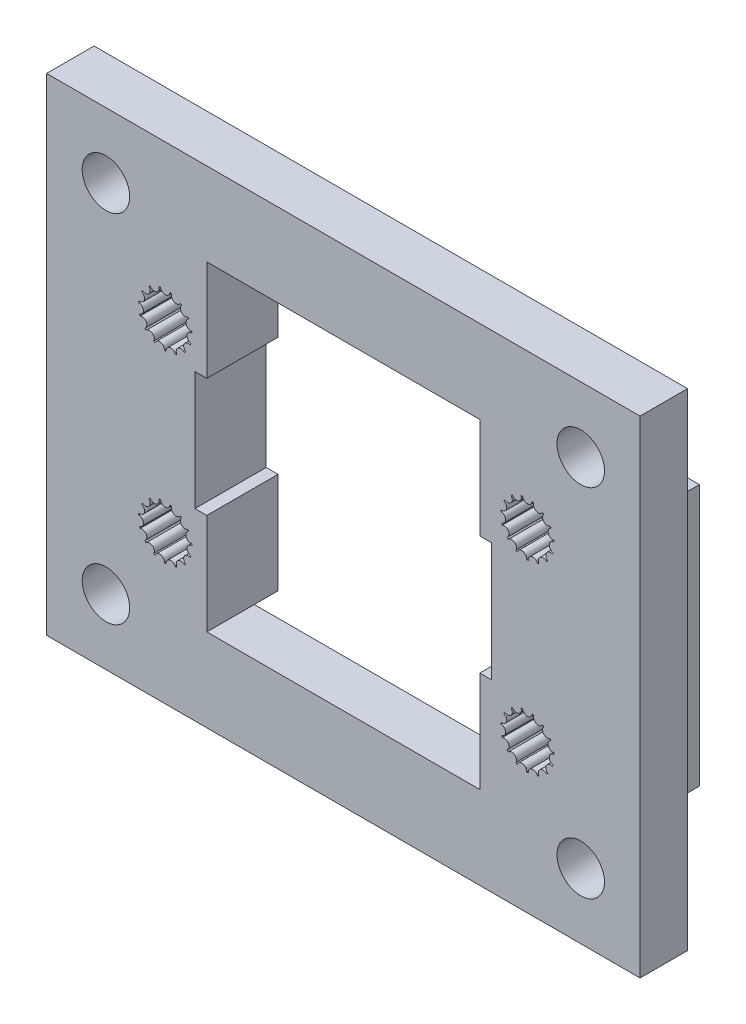
from build123d import *

# Parameters (mm, degrees)
SKETCH3_W               = 50
SKETCH3_H               = 35
BOSS_EXTRUDE2_DEPTH     = 10
CUT_EXTRUDE1_DEPTH      = 16
LPATTERN1_COUNT         = 2
LPATTERN1_PITCH         = 15.5
LPATTERN1_COUNT_DIR2    = 2
LPATTERN1_PITCH_DIR2    = 30.51
SKETCH4_W               = 50
SKETCH4_H               = 35
SKETCH4_W_2             = 42
SKETCH4_H_2             = 27
CUT_EXTRUDE2_DEPTH      = 6
SKETCH5_W               = 25
SKETCH5_H               = 10
CUT_EXTRUDE4_DEPTH      = 24
SKETCH6_R               = 2
CUT_EXTRUDE5_DEPTH      = 24
CUT_EXTRUDE6_DEPTH      = 24
MIRROR2_COPY_1_SKETCH_R = 2
MIRROR2_COPY_1_DEPTH    = 24
MIRROR2_COPY_2_DEPTH    = 24
SKETCH9_W               = 50
SKETCH9_H               = 3
BOSS_EXTRUDE4_DEPTH     = 4
SKETCH10_W              = 43
SKETCH10_H              = 28
CUT_EXTRUDE7_DEPTH      = 4
SKETCH11_W              = 2
SKETCH11_H              = 22
BOSS_EXTRUDE5_DEPTH     = 3
SKETCH12_W              = 23
SKETCH12_H              = 27
CUT_EXTRUDE8_DEPTH      = 17
SKETCH13_W              = 43.2
SKETCH13_H              = 32.4
CUT_EXTRUDE9_DEPTH      = 1


with BuildPart() as part:
    # Sketch3 → Boss-Extrude2 (new body)
    with BuildSketch(Plane.XY):
        with Locations((15, 7.5)):
            Rectangle(SKETCH3_W, SKETCH3_H)
    extrude(amount=BOSS_EXTRUDE2_DEPTH)

    # Sketch1 → Cut-Extrude1 (cut)
    with BuildSketch(Plane.XY):
        with BuildLine():
            ThreePointArc((0.398416619, 17.214444444), (0, 16.85), (-0.398416619, 17.214444444))
            ThreePointArc((-0.398416619, 17.214444444), (-0.467801304, 17.200832102), (-0.536724007, 17.185046302))
            ThreePointArc((-0.536724007, 17.185046302), (-0.75246279, 16.690059097), (-1.264667392, 16.860945025))
            ThreePointArc((-1.264667392, 16.860945025), (-1.322516818, 16.820288237), (-1.379060176, 16.777833803))
            ThreePointArc((-1.379060176, 16.777833803), (-1.374817927, 16.237891622), (-1.912245684, 16.185671305))
            ThreePointArc((-1.912245684, 16.185671305), (-1.948557159, 16.125), (-1.982944313, 16.063217688))
            ThreePointArc((-1.982944313, 16.063217688), (-1.759454555, 15.57168144), (-2.229179325, 15.305384245))
            ThreePointArc((-2.229179325, 15.305384245), (-2.237674265, 15.235189042), (-2.243959363, 15.164761577))
            ThreePointArc((-2.243959363, 15.164761577), (-1.839865506, 14.806622343), (-2.160667609, 14.372293474))
            ThreePointArc((-2.160667609, 14.372293474), (-2.139877162, 14.304711763), (-2.116973454, 14.237816691))
            ThreePointArc((-2.116973454, 14.237816691), (-1.602146997, 14.075), (-1.718556835, 13.547738864))
            ThreePointArc((-1.718556835, 13.547738864), (-1.672075857, 13.494456136), (-1.623943602, 13.442660224))
            ThreePointArc((-1.623943602, 13.442660224), (-1.087402717, 13.50331856), (-0.979291971, 12.974293398))
            ThreePointArc((-0.979291971, 12.974293398), (-0.915157447, 12.94452272), (-0.850119149, 12.916781953))
            ThreePointArc((-0.850119149, 12.916781953), (-0.384636628, 13.190426939), (-0.070698628, 12.751111007))
            ThreePointArc((-0.070698628, 12.751111007), (0, 12.75), (0.070698628, 12.751111007))
            ThreePointArc((0.070698628, 12.751111007), (0.384636628, 13.190426939), (0.850119149, 12.916781953))
            ThreePointArc((0.850119149, 12.916781953), (0.915157447, 12.94452272), (0.979291971, 12.974293398))
            ThreePointArc((0.979291971, 12.974293398), (1.087402717, 13.50331856), (1.623943602, 13.442660224))
            ThreePointArc((1.623943602, 13.442660224), (1.672075857, 13.494456136), (1.718556835, 13.547738864))
            ThreePointArc((1.718556835, 13.547738864), (1.602146997, 14.075), (2.116973454, 14.237816691))
            ThreePointArc((2.116973454, 14.237816691), (2.139877162, 14.304711763), (2.160667609, 14.372293474))
            ThreePointArc((2.160667609, 14.372293474), (1.839865506, 14.806622343), (2.243959363, 15.164761577))
            ThreePointArc((2.243959363, 15.164761577), (2.237674265, 15.235189042), (2.229179325, 15.305384245))
            ThreePointArc((2.229179325, 15.305384245), (1.759454555, 15.57168144), (1.982944313, 16.063217688))
            ThreePointArc((1.982944313, 16.063217688), (1.948557159, 16.125), (1.912245684, 16.185671305))
            ThreePointArc((1.912245684, 16.185671305), (1.374817927, 16.237891622), (1.379060176, 16.777833803))
            ThreePointArc((1.379060176, 16.777833803), (1.322516818, 16.820288237), (1.264667392, 16.860945025))
            ThreePointArc((1.264667392, 16.860945025), (0.75246279, 16.690059097), (0.536724007, 17.185046302))
            ThreePointArc((0.536724007, 17.185046302), (0.467801304, 17.200832102), (0.398416619, 17.214444444))
        make_face()
    cut_extrude1 = extrude(amount=CUT_EXTRUDE1_DEPTH, mode=Mode.SUBTRACT)

    # LPattern1: Cut-Extrude1 2 × 2
    with Locations(*[(j * LPATTERN1_PITCH_DIR2, -i * LPATTERN1_PITCH, 0) for i in range(LPATTERN1_COUNT) for j in range(LPATTERN1_COUNT_DIR2) if (i, j) != (0, 0)]):
        add(cut_extrude1, mode=Mode.SUBTRACT)

    # Sketch4 → Cut-Extrude2 (cut)
    with BuildSketch(Plane(origin=(0, 0, 0), x_dir=(-1, 0, 0), z_dir=(0, 0, -1))):
        with Locations((-15, 7.5)):
            Rectangle(SKETCH4_W, SKETCH4_H)
        with Locations((-15, 7.5)):
            Rectangle(SKETCH4_W_2, SKETCH4_H_2, mode=Mode.SUBTRACT)
    extrude(amount=-CUT_EXTRUDE2_DEPTH, mode=Mode.SUBTRACT)

    # Sketch5 → Cut-Extrude4 (cut)
    with BuildSketch(Plane(origin=(0, 0, 0), x_dir=(-1, 0, 0), z_dir=(0, 0, -1))):
        with Locations((-15, 7.5)):
            Rectangle(SKETCH5_W, SKETCH5_H)
    extrude(amount=-CUT_EXTRUDE4_DEPTH, mode=Mode.SUBTRACT)

    # Sketch6 → Cut-Extrude5 (cut, symmetric)
    with BuildSketch(Plane(origin=(0, 0, 6), x_dir=(-1, 0, 0), z_dir=(0, 0, -1))):
        with Locations((5, 22.5)):
            Circle(SKETCH6_R)
    cut_extrude5 = extrude(amount=CUT_EXTRUDE5_DEPTH, both=True, mode=Mode.SUBTRACT)

    # Sketch7 → Cut-Extrude6 (cut)
    with BuildSketch(Plane(origin=(0, 0, 6), x_dir=(-1, 0, 0), z_dir=(0, 0, -1))):
        with BuildLine():
            Line((5, 25), (10, 25))
            Line((10, 25), (10, 20.5))
            Line((10, 20.5), (10, 18.5))
            Line((10, 18.5), (5, 18.5))
            ThreePointArc((5, 18.5), (2.763932023, 19.18337521), (1.291900756, 21))
            Line((1.291900756, 21), (1.291900756, 25))
            Line((1.291900756, 25), (5, 25))
        make_face()
    cut_extrude6 = extrude(amount=CUT_EXTRUDE6_DEPTH, mode=Mode.SUBTRACT)

    # Mirror1: Cut-Extrude5, Cut-Extrude6 across plane
    add(cut_extrude5.mirror(Plane.ZY.offset(-15)), mode=Mode.SUBTRACT)
    add(cut_extrude6.mirror(Plane.ZY.offset(-15)), mode=Mode.SUBTRACT)

    # Mirror2: Cut-Extrude5, Cut-Extrude6 across plane
    add(cut_extrude5.mirror(Plane(origin=(0, 7.5, 0), x_dir=(0, 0, 1), z_dir=(0, -1, 0))), mode=Mode.SUBTRACT)
    add(cut_extrude6.mirror(Plane(origin=(0, 7.5, 0), x_dir=(0, 0, 1), z_dir=(0, -1, 0))), mode=Mode.SUBTRACT)

    # Mirror2 copy 1 sketch → Mirror2 copy 1 (cut, symmetric)
    with BuildSketch(Plane(origin=(30, 15, 6), x_dir=(1, 0, 0), z_dir=(0, 0, -1))):
        with Locations((5, 22.5)):
            Circle(MIRROR2_COPY_1_SKETCH_R)
    extrude(amount=MIRROR2_COPY_1_DEPTH, both=True, mode=Mode.SUBTRACT)

    # Mirror2 copy 2 sketch → Mirror2 copy 2 (cut)
    with BuildSketch(Plane(origin=(30, 15, 6), x_dir=(1, 0, 0), z_dir=(0, 0, -1))):
        with BuildLine():
            Line((5, 25), (10, 25))
            Line((10, 25), (10, 20.5))
            Line((10, 20.5), (10, 18.5))
            Line((10, 18.5), (5, 18.5))
            ThreePointArc((5, 18.5), (2.763932023, 19.18337521), (1.291900756, 21))
            Line((1.291900756, 21), (1.291900756, 25))
            Line((1.291900756, 25), (5, 25))
        make_face()
    extrude(amount=MIRROR2_COPY_2_DEPTH, mode=Mode.SUBTRACT)

    # Sketch9 → Boss-Extrude4 (add)
    with BuildSketch(Plane(origin=(0, 0, 6), x_dir=(-1, 0, 0), z_dir=(0, 0, -1))):
        with Locations((-15, -11.5)):
            Rectangle(SKETCH9_W, SKETCH9_H)
        with Locations((-15, 26.5)):
            Rectangle(SKETCH9_W, SKETCH9_H)
    extrude(amount=-BOSS_EXTRUDE4_DEPTH)

    # Sketch10 → Cut-Extrude7 (cut)
    with BuildSketch(Plane(origin=(0, 0, 0), x_dir=(-1, 0, 0), z_dir=(0, 0, -1))):
        with Locations((-15, 7.5)):
            Rectangle(SKETCH10_W, SKETCH10_H)
    extrude(amount=-CUT_EXTRUDE7_DEPTH, mode=Mode.SUBTRACT)

    # Sketch11 → Boss-Extrude5 (add)
    with BuildSketch(Plane(origin=(0, 0, 6), x_dir=(-1, 0, 0), z_dir=(0, 0, -1))):
        with Locations((7, 7.5)):
            Rectangle(SKETCH11_W, SKETCH11_H)
        with Locations((-37, 7.5)):
            Rectangle(SKETCH11_W, SKETCH11_H)
    extrude(amount=BOSS_EXTRUDE5_DEPTH)

    # Sketch12 → Cut-Extrude8 (cut)
    with BuildSketch(Plane(origin=(0, 0, 4), x_dir=(-1, 0, 0), z_dir=(0, 0, -1))):
        with Locations((-15, 7.5)):
            Rectangle(SKETCH12_W, SKETCH12_H)
    extrude(amount=-CUT_EXTRUDE8_DEPTH, mode=Mode.SUBTRACT)

    # Sketch13 → Cut-Extrude9 (cut)
    with BuildSketch(Plane(origin=(0, 0, 3), x_dir=(-1, 0, 0), z_dir=(0, 0, -1))):
        with Locations((-15, 7.5)):
            Rectangle(SKETCH13_W, SKETCH13_H)
    extrude(amount=-CUT_EXTRUDE9_DEPTH, mode=Mode.SUBTRACT)


solid = part.part
